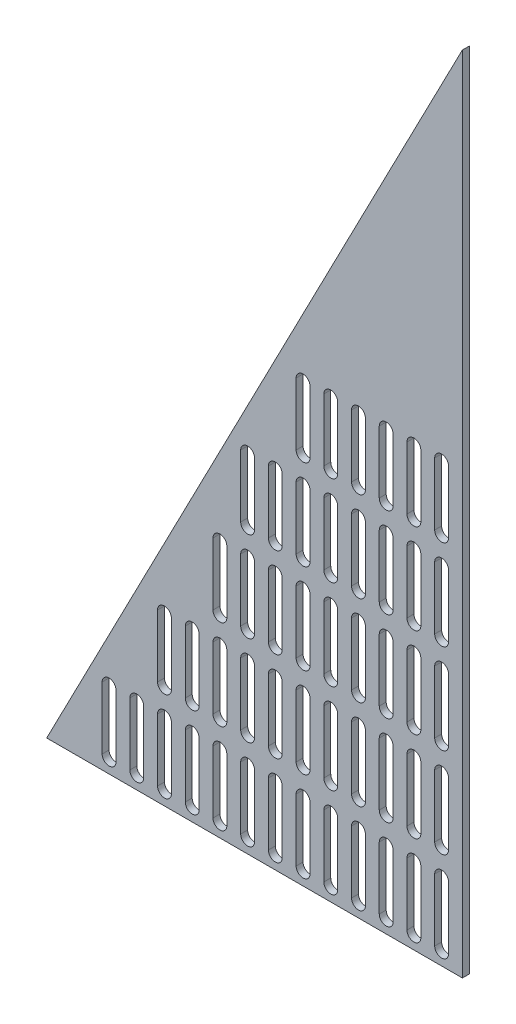
from build123d import *

# Parameters (mm, degrees)
BOSS_EXTRUDE1_DEPTH = 6.35
CUT_EXTRUDE1_DEPTH  = 7.35


with BuildPart() as part:
    # Sketch1 → Boss-Extrude1 (new body)
    with BuildSketch(Plane.XY):
        Polygon((0, 0), (0, 736.6), (-381, 0), align=None)
    extrude(amount=BOSS_EXTRUDE1_DEPTH)

    # Sketch2 → Cut-Extrude1 (cut, through all)
    with BuildSketch(Plane.XY.offset(6.35)):
        with BuildLine():
            Line((-25.4, 12.7), (-25.4, 69.85))
            ThreePointArc((-25.4, 69.85), (-19.05, 76.2), (-12.7, 69.85))
            Line((-12.7, 69.85), (-12.7, 12.7))
            ThreePointArc((-12.7, 12.7), (-19.05, 6.35), (-25.4, 12.7))
        make_face()
        with BuildLine():
            Line((-38.1, 12.7), (-38.1, 69.85))
            ThreePointArc((-38.1, 69.85), (-44.45, 76.2), (-50.8, 69.85))
            Line((-50.8, 69.85), (-50.8, 12.7))
            ThreePointArc((-50.8, 12.7), (-44.45, 6.35), (-38.1, 12.7))
        make_face()
        with BuildLine():
            Line((-63.5, 12.7), (-63.5, 69.85))
            ThreePointArc((-63.5, 69.85), (-69.85, 76.2), (-76.2, 69.85))
            Line((-76.2, 69.85), (-76.2, 12.7))
            ThreePointArc((-76.2, 12.7), (-69.85, 6.35), (-63.5, 12.7))
        make_face()
        with BuildLine():
            Line((-88.9, 12.7), (-88.9, 69.85))
            ThreePointArc((-88.9, 69.85), (-95.25, 76.2), (-101.6, 69.85))
            Line((-101.6, 69.85), (-101.6, 12.7))
            ThreePointArc((-101.6, 12.7), (-95.25, 6.35), (-88.9, 12.7))
        make_face()
        with BuildLine():
            Line((-114.3, 12.7), (-114.3, 69.85))
            ThreePointArc((-114.3, 69.85), (-120.65, 76.2), (-127, 69.85))
            Line((-127, 69.85), (-127, 12.7))
            ThreePointArc((-127, 12.7), (-120.65, 6.35), (-114.3, 12.7))
        make_face()
        with BuildLine():
            Line((-139.7, 12.7), (-139.7, 69.85))
            ThreePointArc((-139.7, 69.85), (-146.05, 76.2), (-152.4, 69.85))
            Line((-152.4, 69.85), (-152.4, 12.7))
            ThreePointArc((-152.4, 12.7), (-146.05, 6.35), (-139.7, 12.7))
        make_face()
        with BuildLine():
            Line((-165.1, 12.7), (-165.1, 69.85))
            ThreePointArc((-165.1, 69.85), (-171.45, 76.2), (-177.8, 69.85))
            Line((-177.8, 69.85), (-177.8, 12.7))
            ThreePointArc((-177.8, 12.7), (-171.45, 6.35), (-165.1, 12.7))
        make_face()
        with BuildLine():
            Line((-190.5, 12.7), (-190.5, 69.85))
            ThreePointArc((-190.5, 69.85), (-196.85, 76.2), (-203.2, 69.85))
            Line((-203.2, 69.85), (-203.2, 12.7))
            ThreePointArc((-203.2, 12.7), (-196.85, 6.35), (-190.5, 12.7))
        make_face()
        with BuildLine():
            Line((-215.9, 12.7), (-215.9, 69.85))
            ThreePointArc((-215.9, 69.85), (-222.25, 76.2), (-228.6, 69.85))
            Line((-228.6, 69.85), (-228.6, 12.7))
            ThreePointArc((-228.6, 12.7), (-222.25, 6.35), (-215.9, 12.7))
        make_face()
        with BuildLine():
            Line((-241.3, 12.7), (-241.3, 69.85))
            ThreePointArc((-241.3, 69.85), (-247.65, 76.2), (-254, 69.85))
            Line((-254, 69.85), (-254, 12.7))
            ThreePointArc((-254, 12.7), (-247.65, 6.35), (-241.3, 12.7))
        make_face()
        with BuildLine():
            Line((-266.7, 12.7), (-266.7, 69.85))
            ThreePointArc((-266.7, 69.85), (-273.05, 76.2), (-279.4, 69.85))
            Line((-279.4, 69.85), (-279.4, 12.7))
            ThreePointArc((-279.4, 12.7), (-273.05, 6.35), (-266.7, 12.7))
        make_face()
        with BuildLine():
            Line((-292.1, 12.7), (-292.1, 69.85))
            ThreePointArc((-292.1, 69.85), (-298.45, 76.2), (-304.8, 69.85))
            Line((-304.8, 69.85), (-304.8, 12.7))
            ThreePointArc((-304.8, 12.7), (-298.45, 6.35), (-292.1, 12.7))
        make_face()
        with BuildLine():
            Line((-317.5, 12.7), (-317.5, 69.85))
            ThreePointArc((-317.5, 69.85), (-323.85, 76.2), (-330.2, 69.85))
            Line((-330.2, 69.85), (-330.2, 12.7))
            ThreePointArc((-330.2, 12.7), (-323.85, 6.35), (-317.5, 12.7))
        make_face()
        with BuildLine():
            Line((-38.1, 95.25), (-38.1, 152.4))
            ThreePointArc((-38.1, 152.4), (-44.45, 158.75), (-50.8, 152.4))
            Line((-50.8, 152.4), (-50.8, 95.25))
            ThreePointArc((-50.8, 95.25), (-44.45, 88.9), (-38.1, 95.25))
        make_face()
        with BuildLine():
            Line((-63.5, 95.25), (-63.5, 152.4))
            ThreePointArc((-63.5, 152.4), (-69.85, 158.75), (-76.2, 152.4))
            Line((-76.2, 152.4), (-76.2, 95.25))
            ThreePointArc((-76.2, 95.25), (-69.85, 88.9), (-63.5, 95.25))
        make_face()
        with BuildLine():
            Line((-88.9, 95.25), (-88.9, 152.4))
            ThreePointArc((-88.9, 152.4), (-95.25, 158.75), (-101.6, 152.4))
            Line((-101.6, 152.4), (-101.6, 95.25))
            ThreePointArc((-101.6, 95.25), (-95.25, 88.9), (-88.9, 95.25))
        make_face()
        with BuildLine():
            Line((-114.3, 95.25), (-114.3, 152.4))
            ThreePointArc((-114.3, 152.4), (-120.65, 158.75), (-127, 152.4))
            Line((-127, 152.4), (-127, 95.25))
            ThreePointArc((-127, 95.25), (-120.65, 88.9), (-114.3, 95.25))
        make_face()
        with BuildLine():
            Line((-139.7, 95.25), (-139.7, 152.4))
            ThreePointArc((-139.7, 152.4), (-146.05, 158.75), (-152.4, 152.4))
            Line((-152.4, 152.4), (-152.4, 95.25))
            ThreePointArc((-152.4, 95.25), (-146.05, 88.9), (-139.7, 95.25))
        make_face()
        with BuildLine():
            Line((-165.1, 95.25), (-165.1, 152.4))
            ThreePointArc((-165.1, 152.4), (-171.45, 158.75), (-177.8, 152.4))
            Line((-177.8, 152.4), (-177.8, 95.25))
            ThreePointArc((-177.8, 95.25), (-171.45, 88.9), (-165.1, 95.25))
        make_face()
        with BuildLine():
            Line((-190.5, 95.25), (-190.5, 152.4))
            ThreePointArc((-190.5, 152.4), (-196.85, 158.75), (-203.2, 152.4))
            Line((-203.2, 152.4), (-203.2, 95.25))
            ThreePointArc((-203.2, 95.25), (-196.85, 88.9), (-190.5, 95.25))
        make_face()
        with BuildLine():
            Line((-215.9, 95.25), (-215.9, 152.4))
            ThreePointArc((-215.9, 152.4), (-222.25, 158.75), (-228.6, 152.4))
            Line((-228.6, 152.4), (-228.6, 95.25))
            ThreePointArc((-228.6, 95.25), (-222.25, 88.9), (-215.9, 95.25))
        make_face()
        with BuildLine():
            Line((-241.3, 95.25), (-241.3, 152.4))
            ThreePointArc((-241.3, 152.4), (-247.65, 158.75), (-254, 152.4))
            Line((-254, 152.4), (-254, 95.25))
            ThreePointArc((-254, 95.25), (-247.65, 88.9), (-241.3, 95.25))
        make_face()
        with BuildLine():
            Line((-266.7, 95.25), (-266.7, 152.4))
            ThreePointArc((-266.7, 152.4), (-273.05, 158.75), (-279.4, 152.4))
            Line((-279.4, 152.4), (-279.4, 95.25))
            ThreePointArc((-279.4, 95.25), (-273.05, 88.9), (-266.7, 95.25))
        make_face()
        with BuildLine():
            Line((-38.1, 177.8), (-38.1, 234.95))
            ThreePointArc((-38.1, 234.95), (-44.45, 241.3), (-50.8, 234.95))
            Line((-50.8, 234.95), (-50.8, 177.8))
            ThreePointArc((-50.8, 177.8), (-44.45, 171.45), (-38.1, 177.8))
        make_face()
        with BuildLine():
            Line((-63.5, 177.8), (-63.5, 234.95))
            ThreePointArc((-63.5, 234.95), (-69.85, 241.3), (-76.2, 234.95))
            Line((-76.2, 234.95), (-76.2, 177.8))
            ThreePointArc((-76.2, 177.8), (-69.85, 171.45), (-63.5, 177.8))
        make_face()
        with BuildLine():
            Line((-88.9, 177.8), (-88.9, 234.95))
            ThreePointArc((-88.9, 234.95), (-95.25, 241.3), (-101.6, 234.95))
            Line((-101.6, 234.95), (-101.6, 177.8))
            ThreePointArc((-101.6, 177.8), (-95.25, 171.45), (-88.9, 177.8))
        make_face()
        with BuildLine():
            Line((-114.3, 177.8), (-114.3, 234.95))
            ThreePointArc((-114.3, 234.95), (-120.65, 241.3), (-127, 234.95))
            Line((-127, 234.95), (-127, 177.8))
            ThreePointArc((-127, 177.8), (-120.65, 171.45), (-114.3, 177.8))
        make_face()
        with BuildLine():
            Line((-139.7, 177.8), (-139.7, 234.95))
            ThreePointArc((-139.7, 234.95), (-146.05, 241.3), (-152.4, 234.95))
            Line((-152.4, 234.95), (-152.4, 177.8))
            ThreePointArc((-152.4, 177.8), (-146.05, 171.45), (-139.7, 177.8))
        make_face()
        with BuildLine():
            Line((-165.1, 177.8), (-165.1, 234.95))
            ThreePointArc((-165.1, 234.95), (-171.45, 241.3), (-177.8, 234.95))
            Line((-177.8, 234.95), (-177.8, 177.8))
            ThreePointArc((-177.8, 177.8), (-171.45, 171.45), (-165.1, 177.8))
        make_face()
        with BuildLine():
            Line((-190.5, 177.8), (-190.5, 234.95))
            ThreePointArc((-190.5, 234.95), (-196.85, 241.3), (-203.2, 234.95))
            Line((-203.2, 234.95), (-203.2, 177.8))
            ThreePointArc((-203.2, 177.8), (-196.85, 171.45), (-190.5, 177.8))
        make_face()
        with BuildLine():
            Line((-215.9, 177.8), (-215.9, 234.95))
            ThreePointArc((-215.9, 234.95), (-222.25, 241.3), (-228.6, 234.95))
            Line((-228.6, 234.95), (-228.6, 177.8))
            ThreePointArc((-228.6, 177.8), (-222.25, 171.45), (-215.9, 177.8))
        make_face()
        with BuildLine():
            Line((-38.1, 260.35), (-38.1, 317.5))
            ThreePointArc((-38.1, 317.5), (-44.45, 323.85), (-50.8, 317.5))
            Line((-50.8, 317.5), (-50.8, 260.35))
            ThreePointArc((-50.8, 260.35), (-44.45, 254), (-38.1, 260.35))
        make_face()
        with BuildLine():
            Line((-63.5, 260.35), (-63.5, 317.5))
            ThreePointArc((-63.5, 317.5), (-69.85, 323.85), (-76.2, 317.5))
            Line((-76.2, 317.5), (-76.2, 260.35))
            ThreePointArc((-76.2, 260.35), (-69.85, 254), (-63.5, 260.35))
        make_face()
        with BuildLine():
            Line((-88.9, 260.35), (-88.9, 317.5))
            ThreePointArc((-88.9, 317.5), (-95.25, 323.85), (-101.6, 317.5))
            Line((-101.6, 317.5), (-101.6, 260.35))
            ThreePointArc((-101.6, 260.35), (-95.25, 254), (-88.9, 260.35))
        make_face()
        with BuildLine():
            Line((-114.3, 260.35), (-114.3, 317.5))
            ThreePointArc((-114.3, 317.5), (-120.65, 323.85), (-127, 317.5))
            Line((-127, 317.5), (-127, 260.35))
            ThreePointArc((-127, 260.35), (-120.65, 254), (-114.3, 260.35))
        make_face()
        with BuildLine():
            Line((-139.7, 260.35), (-139.7, 317.5))
            ThreePointArc((-139.7, 317.5), (-146.05, 323.85), (-152.4, 317.5))
            Line((-152.4, 317.5), (-152.4, 260.35))
            ThreePointArc((-152.4, 260.35), (-146.05, 254), (-139.7, 260.35))
        make_face()
        with BuildLine():
            Line((-165.1, 260.35), (-165.1, 317.5))
            ThreePointArc((-165.1, 317.5), (-171.45, 323.85), (-177.8, 317.5))
            Line((-177.8, 317.5), (-177.8, 260.35))
            ThreePointArc((-177.8, 260.35), (-171.45, 254), (-165.1, 260.35))
        make_face()
        with BuildLine():
            Line((-190.5, 260.35), (-190.5, 317.5))
            ThreePointArc((-190.5, 317.5), (-196.85, 323.85), (-203.2, 317.5))
            Line((-203.2, 317.5), (-203.2, 260.35))
            ThreePointArc((-203.2, 260.35), (-196.85, 254), (-190.5, 260.35))
        make_face()
        with BuildLine():
            Line((-38.1, 342.9), (-38.1, 400.05))
            ThreePointArc((-38.1, 400.05), (-44.45, 406.4), (-50.8, 400.05))
            Line((-50.8, 400.05), (-50.8, 342.9))
            ThreePointArc((-50.8, 342.9), (-44.45, 336.55), (-38.1, 342.9))
        make_face()
        with BuildLine():
            Line((-63.5, 342.9), (-63.5, 400.05))
            ThreePointArc((-63.5, 400.05), (-69.85, 406.4), (-76.2, 400.05))
            Line((-76.2, 400.05), (-76.2, 342.9))
            ThreePointArc((-76.2, 342.9), (-69.85, 336.55), (-63.5, 342.9))
        make_face()
        with BuildLine():
            Line((-88.9, 342.9), (-88.9, 400.05))
            ThreePointArc((-88.9, 400.05), (-95.25, 406.4), (-101.6, 400.05))
            Line((-101.6, 400.05), (-101.6, 342.9))
            ThreePointArc((-101.6, 342.9), (-95.25, 336.55), (-88.9, 342.9))
        make_face()
        with BuildLine():
            Line((-114.3, 342.9), (-114.3, 400.05))
            ThreePointArc((-114.3, 400.05), (-120.65, 406.4), (-127, 400.05))
            Line((-127, 400.05), (-127, 342.9))
            ThreePointArc((-127, 342.9), (-120.65, 336.55), (-114.3, 342.9))
        make_face()
        with BuildLine():
            Line((-139.7, 342.9), (-139.7, 400.05))
            ThreePointArc((-139.7, 400.05), (-146.05, 406.4), (-152.4, 400.05))
            Line((-152.4, 400.05), (-152.4, 342.9))
            ThreePointArc((-152.4, 342.9), (-146.05, 336.55), (-139.7, 342.9))
        make_face()
        with BuildLine():
            Line((-12.7, 95.25), (-12.7, 152.4))
            ThreePointArc((-12.7, 152.4), (-19.05, 158.75), (-25.4, 152.4))
            Line((-25.4, 152.4), (-25.4, 95.25))
            ThreePointArc((-25.4, 95.25), (-19.05, 88.9), (-12.7, 95.25))
        make_face()
        with BuildLine():
            Line((-12.7, 177.8), (-12.7, 234.95))
            ThreePointArc((-12.7, 234.95), (-19.05, 241.3), (-25.4, 234.95))
            Line((-25.4, 234.95), (-25.4, 177.8))
            ThreePointArc((-25.4, 177.8), (-19.05, 171.45), (-12.7, 177.8))
        make_face()
        with BuildLine():
            Line((-12.7, 260.35), (-12.7, 317.5))
            ThreePointArc((-12.7, 317.5), (-19.05, 323.85), (-25.4, 317.5))
            Line((-25.4, 317.5), (-25.4, 260.35))
            ThreePointArc((-25.4, 260.35), (-19.05, 254), (-12.7, 260.35))
        make_face()
        with BuildLine():
            Line((-12.7, 342.9), (-12.7, 400.05))
            ThreePointArc((-12.7, 400.05), (-19.05, 406.4), (-25.4, 400.05))
            Line((-25.4, 400.05), (-25.4, 342.9))
            ThreePointArc((-25.4, 342.9), (-19.05, 336.55), (-12.7, 342.9))
        make_face()
    extrude(amount=-CUT_EXTRUDE1_DEPTH, mode=Mode.SUBTRACT)


solid = part.part
